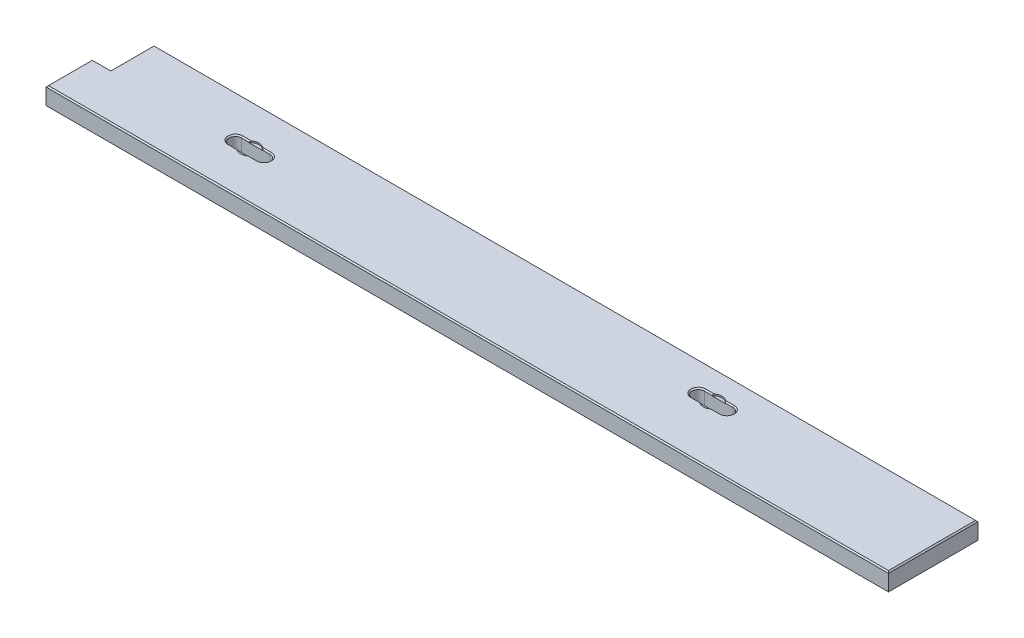
from build123d import *

# Parameters (mm, degrees)
SKETCH1_W           = 1695.45
SKETCH1_H           = 184.15
BOSS_EXTRUDE1_DEPTH = 38.1
SKETCH2_W           = 38.1
SKETCH2_H           = 95.25
BOSS_EXTRUDE3_DEPTH = 38.1
CHAMFER1_SIZE       = 2.54
CHAMFER2_SIZE       = 2.54
SKETCH3_R           = 19.05
CUT_EXTRUDE1_DEPTH  = 3.175


with BuildPart() as part:
    # Sketch1 → Boss-Extrude1 (new body)
    with BuildSketch(Plane(origin=(0, 0, 0), x_dir=(1, 0, 0), z_dir=(0, 1, 0))):
        with Locations((847.725, 92.075)):
            Rectangle(SKETCH1_W, SKETCH1_H)
        with BuildLine():
            Line((1181.2651, 135.56615), (1240.0153, 135.56615))
            ThreePointArc((1240.0153, 135.56615), (1252.7153, 122.86615), (1240.0153, 110.16615))
            Line((1240.0153, 110.16615), (1181.2651, 110.16615))
            ThreePointArc((1181.2651, 110.16615), (1168.5651, 122.86615), (1181.2651, 135.56615))
        make_face(mode=Mode.SUBTRACT)
        with BuildLine():
            Line((254, 110.31855), (312.7502, 110.31855))
            ThreePointArc((312.7502, 110.31855), (325.4502, 97.61855), (312.7502, 84.91855))
            Line((312.7502, 84.91855), (254, 84.91855))
            ThreePointArc((254, 84.91855), (241.3, 97.61855), (254, 110.31855))
        make_face(mode=Mode.SUBTRACT)
    extrude(amount=BOSS_EXTRUDE1_DEPTH)

    # Sketch2 → Boss-Extrude3 (add, through all)
    with BuildSketch(Plane(origin=(0, 38.1, 0), x_dir=(1, 0, 0), z_dir=(0, 1, 0))):
        with Locations((-19.05, 47.625)):
            Rectangle(SKETCH2_W, SKETCH2_H)
    extrude(amount=-BOSS_EXTRUDE3_DEPTH)

    # Chamfer1
    chamfer1_edges = [part.edges().sort_by_distance(p)[0] for p in [
        (1695.45, 38.1, -92.075),
        (1252.7153, 38.1, -122.86615),
        (847.725, 38.1, -184.15),
        (1210.6402, 38.1, -135.56615),
        (1168.5651, 38.1, -122.86615),
        (1210.6402, 38.1, -110.16615),
        (325.4502, 38.1, -97.61855),
        (283.3751, 38.1, -110.31855),
        (241.3, 38.1, -97.61855),
        (283.3751, 38.1, -84.91855),
        (-19.05, 38.1, -95.25),
        (-38.1, 38.1, -47.625),
        (0, 38.1, -139.7),
        (828.675, 38.1, 0),
    ]]
    chamfer(chamfer1_edges, length=CHAMFER1_SIZE)

    # Chamfer2
    chamfer2_edges = [part.edges().sort_by_distance(p)[0] for p in [
        (1252.7153, 0, -122.86615),
        (1210.6402, 0, -135.56615),
        (1168.5651, 0, -122.86615),
        (1210.6402, 0, -110.16615),
        (325.4502, 0, -97.61855),
        (283.3751, 0, -110.31855),
        (241.3, 0, -97.61855),
        (283.3751, 0, -84.91855),
        (-38.1, 0, -47.625),
        (-19.05, 0, -95.25),
        (847.725, 0, -184.15),
        (1695.45, 0, -92.075),
        (828.675, 0, 0),
        (0, 0, -139.7),
    ]]
    chamfer(chamfer2_edges, length=CHAMFER2_SIZE)

    # Sketch3 → Cut-Extrude1 (cut)
    with BuildSketch(Plane(origin=(0, 38.1, 0), x_dir=(1, 0, 0), z_dir=(0, 1, 0))):
        with Locations((1210.6402, 122.86615)):
            Circle(SKETCH3_R)
        with Locations((283.3751, 97.61855)):
            Circle(SKETCH3_R)
    extrude(amount=-CUT_EXTRUDE1_DEPTH, mode=Mode.SUBTRACT)


solid = part.part
